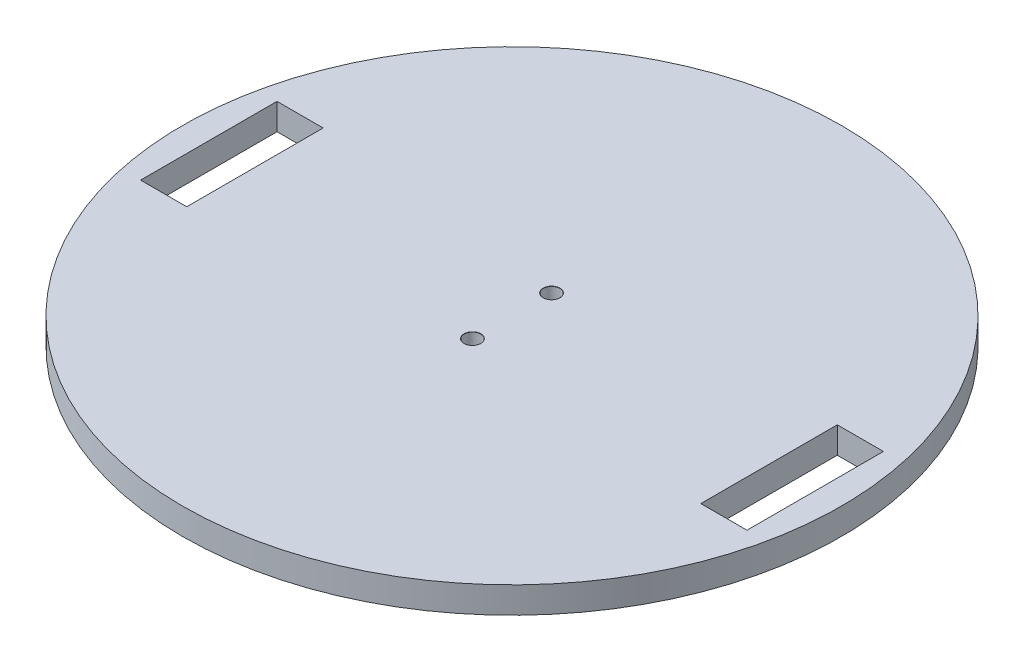
from build123d import *

# Parameters (mm, degrees)
SKETCH2_R                             = 50
BOSS_EXTRUDE2_DEPTH                   = 4
TAP_DRILL_FOR_M3X0_5_TAP1_D           = 2.5
TAP_DRILL_FOR_M3X0_5_TAP1_CSINK_D     = 2.55
TAP_DRILL_FOR_M3X0_5_TAP1_CSINK_ANGLE = 90
SKETCH5_W                             = 7
SKETCH5_H                             = 20.7
CUT_EXTRUDE1_DEPTH                    = 10


with BuildPart() as part:
    # Sketch2 → Boss-Extrude2 (new body)
    with BuildSketch(Plane(origin=(0, 0, 0), x_dir=(1, 0, 0), z_dir=(0, 1, 0))):
        Circle(SKETCH2_R)
    extrude(amount=BOSS_EXTRUDE2_DEPTH)

    # Tap Drill for M3x0.5 Tap1 (through all)
    with Locations(Plane(origin=(0, 4, 0), x_dir=(1, 0, 0), z_dir=(0, 1, 0))):
        with Locations((0, 6), (0, -6)):
            CounterSinkHole(TAP_DRILL_FOR_M3X0_5_TAP1_D / 2, TAP_DRILL_FOR_M3X0_5_TAP1_CSINK_D / 2, counter_sink_angle=TAP_DRILL_FOR_M3X0_5_TAP1_CSINK_ANGLE)

    # Sketch5 → Cut-Extrude1 (cut)
    with BuildSketch(Plane.XZ):
        with Locations((-42.5, 0)):
            Rectangle(SKETCH5_W, SKETCH5_H)
        with Locations((42.5, 0)):
            Rectangle(SKETCH5_W, SKETCH5_H)
    extrude(amount=-CUT_EXTRUDE1_DEPTH, mode=Mode.SUBTRACT)


solid = part.part
